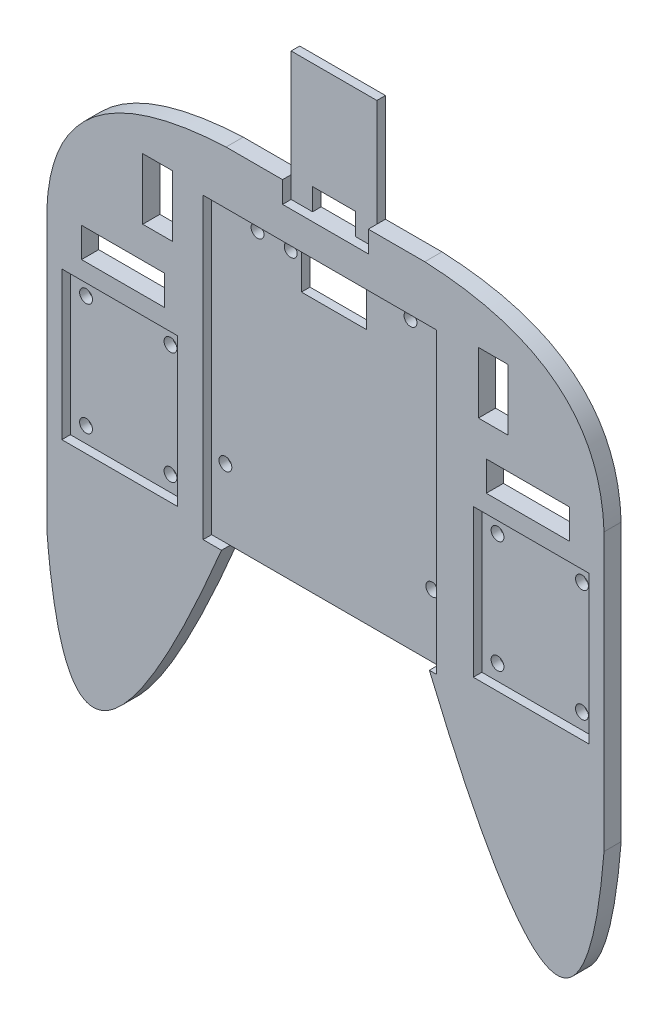
from build123d import *

# Parameters (mm, degrees)
IZIM1_W                     = 130
IZIM1_H                     = 160
Y_KSEKLIK_EKSTR_ZYON1_DEPTH = 4
IZIM3_W                     = 55
IZIM3_H                     = 25
KES_EKSTR_ZYON1_DEPTH       = 4
KES_EKSTR_ZYON2_DEPTH       = 10
IZIM5_W                     = 54.012242348
IZIM5_H                     = 68.899562137
KES_EKSTR_ZYON3_DEPTH       = 2
IZIM8_W                     = 54.469692937
IZIM8_H                     = 69.59441616
KES_EKSTR_ZYON5_DEPTH       = 2
IZIM9_R                     = 1.5
KES_EKSTR_ZYON6_DEPTH       = 5
IZIM10_W                    = 27
IZIM10_H                    = 34.5
KES_EKSTR_ZYON7_DEPTH       = 2
IZIM11_R                    = 1.5
KES_EKSTR_ZYON8_DEPTH       = 5
KES_EKSTR_ZYON9_DEPTH       = 104.155222988
KES_EKSTR_ZYON9_DEPTH_BACK  = 5
KES_EKSTR_ZYON10_DEPTH      = 2
IZIM14_W                    = 5
IZIM14_H                    = 5.1
KES_EKSTR_ZYON11_DEPTH      = 9
IZIM15_W                    = 6.934142085
IZIM15_H                    = 14.276174882
IZIM15_W_2                  = 19.374808768
IZIM15_H_2                  = 6.934142085
KES_EKSTR_ZYON12_DEPTH      = 9
IZIM16_R                    = 1.5
KES_EKSTR_ZYON13_DEPTH      = 10
IZIM17_W                    = 7.6
IZIM17_H                    = 8.3
KES_EKSTR_ZYON14_DEPTH      = 10


with BuildPart() as part:
    # Çizim1 → Yükseklik-Ekstrüzyon1 (new body)
    with BuildSketch(Plane.XY):
        Rectangle(IZIM1_W, IZIM1_H)
    extrude(amount=Y_KSEKLIK_EKSTR_ZYON1_DEPTH)

    # Çizim3 → Kes-Ekstrüzyon1 (cut)
    with BuildSketch(Plane(origin=(0, 0, 0), x_dir=(-1, 0, 0), z_dir=(0, 0, -1))):
        with Locations((37.5, 67.5)):
            Rectangle(IZIM3_W, IZIM3_H)
        with Locations((-37.5, 67.5)):
            Rectangle(IZIM3_W, IZIM3_H)
    extrude(amount=-KES_EKSTR_ZYON1_DEPTH, mode=Mode.SUBTRACT)

    # Çizim4 → Kes-Ekstrüzyon2 (cut)
    with BuildSketch(Plane.XY.offset(4)):
        with BuildLine():
            Line((-24.249382275, -27.006425474), (24.249382275, -27.006425474))
            add(Edge.make_bspline(
                [(65, -43.244851104), (59.485167295, -111.431741319), (24.249382275, -27.006425474)],
                knots=[0, 0, 0, 1, 1, 1], degree=2))
            Line((65, -43.244851104), (65, -80))
            Line((65, -80), (-65, -80))
            Line((-65, -80), (-65, -43.244851104))
            add(Edge.make_bspline(
                [(-65, -43.244851104), (-59.485167295, -111.431741319), (-24.249382275, -27.006425474)],
                knots=[0, 0, 0, 1, 1, 1], degree=2))
        make_face()
    extrude(amount=-KES_EKSTR_ZYON2_DEPTH, mode=Mode.SUBTRACT)

    # Çizim5 → Kes-Ekstrüzyon3 (cut)
    with BuildSketch(Plane.XY.offset(4)):
        with Locations((-1.54185026, 8.138209618)):
            Rectangle(IZIM5_W, IZIM5_H)
    extrude(amount=-KES_EKSTR_ZYON3_DEPTH, mode=Mode.SUBTRACT)

    # Çizim8 → Kes-Ekstrüzyon5 (cut)
    with BuildSketch(Plane.XY.offset(4)):
        with Locations((-1.313124966, 7.790782606)):
            Rectangle(IZIM8_W, IZIM8_H)
    extrude(amount=-KES_EKSTR_ZYON5_DEPTH, mode=Mode.SUBTRACT)

    # Çizim9 → Kes-Ekstrüzyon6 (cut)
    with BuildSketch(Plane.XY.offset(4)):
        with Locations((-10.095729086, 39.728428549)):
            Circle(IZIM9_R)
        with Locations((17.844270914, 39.728428549)):
            Circle(IZIM9_R)
        with Locations((-25.335729086, -11.071571451)):
            Circle(IZIM9_R)
        with Locations((22.924270914, -12.341571451)):
            Circle(IZIM9_R)
    extrude(amount=-KES_EKSTR_ZYON6_DEPTH, mode=Mode.SUBTRACT)

    # Çizim10 → Kes-Ekstrüzyon7 (cut)
    with BuildSketch(Plane.XY.offset(4)):
        with Locations((-48, -6.037117551)):
            Rectangle(IZIM10_W, IZIM10_H)
        with Locations((48, -6.037117551)):
            Rectangle(IZIM10_W, IZIM10_H)
    extrude(amount=-KES_EKSTR_ZYON7_DEPTH, mode=Mode.SUBTRACT)

    # Çizim11 → Kes-Ekstrüzyon8 (cut)
    with BuildSketch(Plane.XY.offset(4)):
        with Locations((-57.85, -19.637117551)):
            Circle(IZIM11_R)
        with Locations((-38.15, -19.637117551)):
            Circle(IZIM11_R)
        with Locations((-38.15, 6.562882449)):
            Circle(IZIM11_R)
        with Locations((-57.85, 6.562882449)):
            Circle(IZIM11_R)
        with Locations(Location((57.85, -19.637117551, 0), (0, 0, 180))):
            Circle(IZIM11_R)
        with Locations(Location((38.15, -19.637117551, 0), (0, 0, 180))):
            Circle(IZIM11_R)
        with Locations(Location((38.15, 6.562882449, 0), (0, 0, 180))):
            Circle(IZIM11_R)
        with Locations(Location((57.85, 6.562882449, 0), (0, 0, 180))):
            Circle(IZIM11_R)
    extrude(amount=-KES_EKSTR_ZYON8_DEPTH, mode=Mode.SUBTRACT)

    # Çizim12 → Kes-Ekstrüzyon9 (cut, two sides)
    with BuildSketch(Plane.XY.offset(4)) as kes_ekstr_zyon9_sk:
        with BuildLine():
            Line((-65, 55), (-65, 21.312671553))
            add(Edge.make_bspline(
                [(-65, 21.312671553), (-63.962297288, 53.139320322), (-23.182224936, 55)],
                knots=[0, 0, 0, 0.889532369, 0.889532369, 0.889532369], degree=2))
            Line((-23.182224936, 55), (-65, 55))
        make_face()
        with BuildLine():
            add(Edge.make_bspline(
                [(65, 21.312671553), (63.962297288, 53.139320322), (23.182224936, 55)],
                knots=[0, 0, 0, 0.889532369, 0.889532369, 0.889532369], degree=2))
            Line((65, 21.312671553), (65, 55))
            Line((65, 55), (23.182224936, 55))
        make_face()
    extrude(amount=KES_EKSTR_ZYON9_DEPTH, mode=Mode.SUBTRACT)
    extrude(kes_ekstr_zyon9_sk.sketch, amount=-KES_EKSTR_ZYON9_DEPTH_BACK, mode=Mode.SUBTRACT)

    # Çizim13 → Kes-Ekstrüzyon10 (cut)
    with BuildSketch(Plane.XY.offset(4)):
        Polygon((0, 50), (0, 80), (-10, 80), (-10, 55), (-10, 50), align=None)
        Polygon((10, 80), (0, 80), (0, 50), (10, 50), (10, 55), align=None)
    extrude(amount=-KES_EKSTR_ZYON10_DEPTH, mode=Mode.SUBTRACT)

    # Çizim14 → Kes-Ekstrüzyon11 (cut)
    with BuildSketch(Plane.XY.offset(2)):
        with Locations((-2.5, 52.55)):
            Rectangle(IZIM14_W, IZIM14_H)
        with Locations((2.5, 52.55)):
            Rectangle(IZIM14_W, IZIM14_H)
    extrude(amount=-KES_EKSTR_ZYON11_DEPTH, mode=Mode.SUBTRACT)

    # Çizim15 → Kes-Ekstrüzyon12 (cut)
    with BuildSketch(Plane.XY.offset(4)):
        with Locations((-39.157508247, 36.812518567)):
            Rectangle(IZIM15_W, IZIM15_H)
        with Locations((-47.213349787, 18.865327288)):
            Rectangle(IZIM15_W_2, IZIM15_H_2)
        with Locations((39.157508247, 36.812518567)):
            Rectangle(IZIM15_W, IZIM15_H)
        with Locations((47.213349787, 18.865327288)):
            Rectangle(IZIM15_W_2, IZIM15_H_2)
    extrude(amount=-KES_EKSTR_ZYON12_DEPTH, mode=Mode.SUBTRACT)

    # Çizim16 → Kes-Ekstrüzyon13 (cut)
    with BuildSketch(Plane.XY.offset(2)):
        with Locations((-17.844270914, 39.728428549)):
            Circle(IZIM16_R)
    extrude(amount=-KES_EKSTR_ZYON13_DEPTH, mode=Mode.SUBTRACT)

    # Çizim17 → Kes-Ekstrüzyon14 (cut)
    with BuildSketch(Plane.XY.offset(2)):
        with Locations((-3.8, 36.638150808)):
            Rectangle(IZIM17_W, IZIM17_H)
        with Locations((3.8, 36.638150808)):
            Rectangle(IZIM17_W, IZIM17_H)
    extrude(amount=-KES_EKSTR_ZYON14_DEPTH, mode=Mode.SUBTRACT)


solid = part.part
